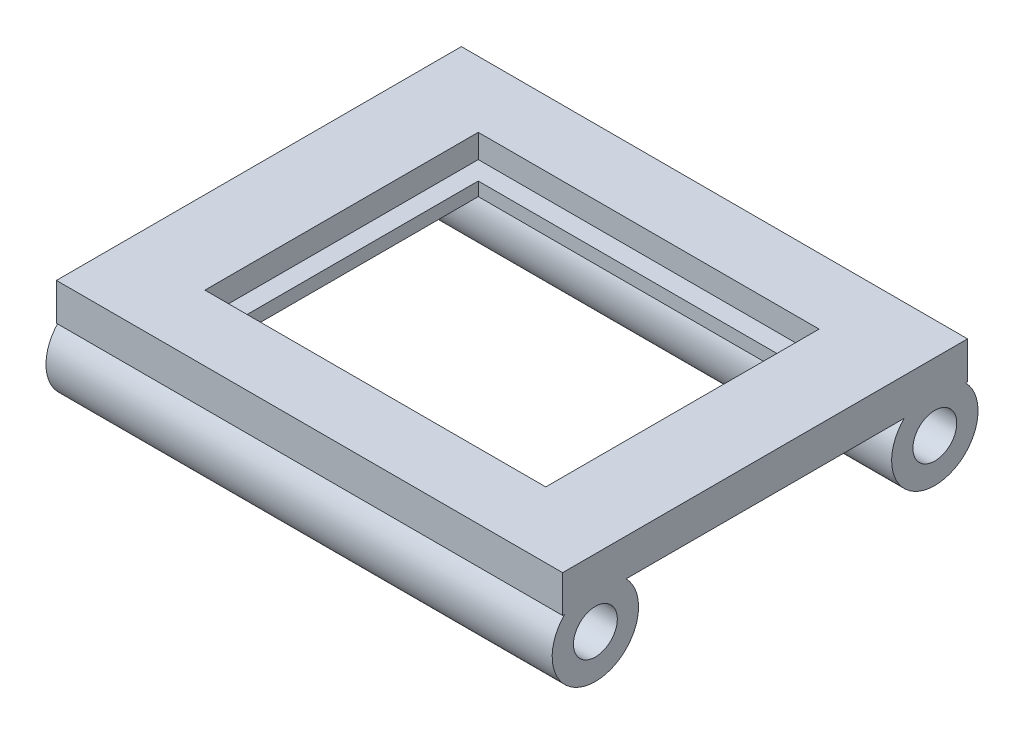
from build123d import *

# Parameters (mm, degrees)
SKETCH3_W           = 150
SKETCH3_H           = 120
BOSS_EXTRUDE1_DEPTH = 11
SKETCH4_W           = 101
SKETCH4_H           = 81
CUT_EXTRUDE1_DEPTH  = 7
SKETCH5_W           = 90
SKETCH5_H           = 70
CUT_EXTRUDE2_DEPTH  = 5
SKETCH7_R           = 6.5
BOSS_EXTRUDE2_DEPTH = 150


with BuildPart() as part:
    # Sketch3 → Boss-Extrude1 (new body)
    with BuildSketch(Plane(origin=(0, 0, 0), x_dir=(1, 0, 0), z_dir=(0, 1, 0))):
        Rectangle(SKETCH3_W, SKETCH3_H)
    extrude(amount=BOSS_EXTRUDE1_DEPTH)

    # Sketch4 → Cut-Extrude1 (cut)
    with BuildSketch(Plane(origin=(0, 11, 0), x_dir=(1, 0, 0), z_dir=(0, 1, 0))):
        Rectangle(SKETCH4_W, SKETCH4_H)
    extrude(amount=-CUT_EXTRUDE1_DEPTH, mode=Mode.SUBTRACT)

    # Sketch5 → Cut-Extrude2 (cut, through all)
    with BuildSketch(Plane(origin=(0, 4, 0), x_dir=(1, 0, 0), z_dir=(0, 1, 0))):
        Rectangle(SKETCH5_W, SKETCH5_H)
    extrude(amount=-CUT_EXTRUDE2_DEPTH, mode=Mode.SUBTRACT)

    # Sketch7 → Boss-Extrude2 (add)
    with BuildSketch(Plane.ZY.offset(75)):
        with BuildLine():
            Line((41.194351798, 0), (59.397648202, 0))
            ThreePointArc((59.397648202, 0), (50.296, -21.8), (41.194351798, 0))
        make_face()
        with Locations((50.296, -9)):
            Circle(SKETCH7_R, mode=Mode.SUBTRACT)
    boss_extrude2 = extrude(amount=-BOSS_EXTRUDE2_DEPTH)

    # Mirror1: Boss-Extrude2 across plane
    add(boss_extrude2.mirror(Plane.XY))


solid = part.part
